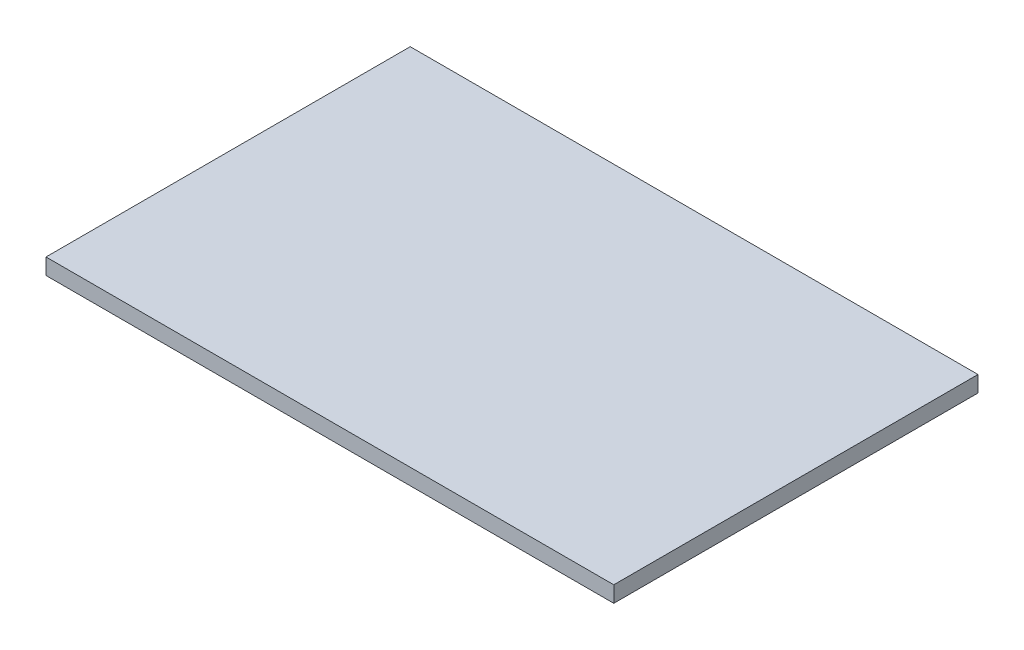
from build123d import *

# Parameters (mm, degrees)
SKETCH2_W           = 134.62
SKETCH2_H           = 86.36
BOSS_EXTRUDE1_DEPTH = 3.81


with BuildPart() as part:
    # Sketch2 → Boss-Extrude1 (new body)
    with BuildSketch(Plane(origin=(0, 0, 0), x_dir=(1, 0, 0), z_dir=(0, 1, 0))):
        with Locations((2845.733478261, 848.124347826)):
            Rectangle(SKETCH2_W, SKETCH2_H)
    extrude(amount=BOSS_EXTRUDE1_DEPTH)


solid = part.part
